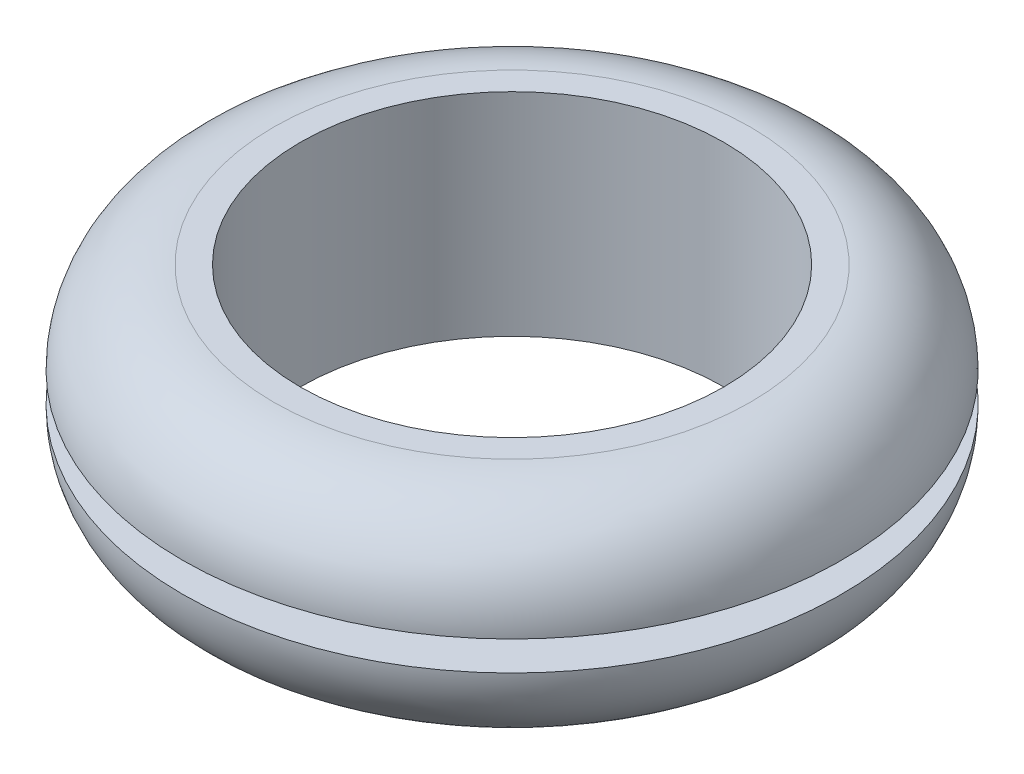
from build123d import *

# Parameters (mm, degrees)
SKETCH2_R           = 14
SKETCH2_R_2         = 9
BOSS_EXTRUDE1_DEPTH = 9
FILLET1_R           = 3.875
CUT_EXTRUDE1_START  = -3.875
SKETCH3_R           = 15.875
SKETCH3_R_2         = 11
CUT_EXTRUDE1_DEPTH  = 1.25


with BuildPart() as part:
    # Sketch2 → Boss-Extrude1 (new body)
    with BuildSketch(Plane(origin=(0, 0, 0), x_dir=(1, 0, 0), z_dir=(0, 1, 0))):
        Circle(SKETCH2_R)
        Circle(SKETCH2_R_2, mode=Mode.SUBTRACT)
    extrude(amount=BOSS_EXTRUDE1_DEPTH)

    # Fillet1
    fillet1_edges = [part.edges().sort_by_distance(p)[0] for p in [
        (-14, 0, 0),
        (-14, 9, 0),
    ]]
    fillet(fillet1_edges, radius=FILLET1_R)

    # Sketch3 → Cut-Extrude1 (cut)
    with BuildSketch(Plane(origin=(0, 9, 0), x_dir=(1, 0, 0), z_dir=(0, 1, 0)).offset(CUT_EXTRUDE1_START)):
        Circle(SKETCH3_R)
        Circle(SKETCH3_R_2, mode=Mode.SUBTRACT)
    extrude(amount=-CUT_EXTRUDE1_DEPTH, mode=Mode.SUBTRACT)


solid = part.part
